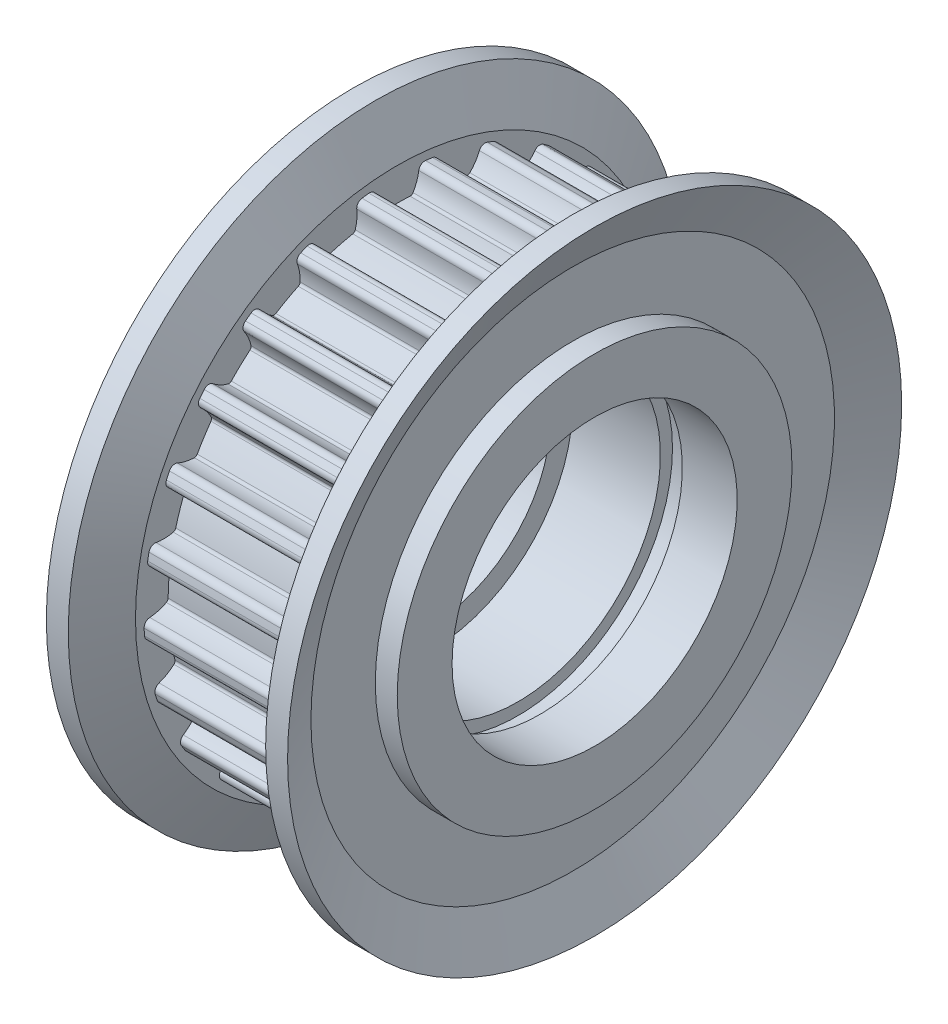
from build123d import *

# Parameters (mm, degrees)
CUT_EXTRUDE1_DEPTH  = 7
CUT_EXTRUDE2_DEPTH  = 7
CUT_EXTRUDE3_DEPTH  = 7
CUT_EXTRUDE4_DEPTH  = 7
CUT_EXTRUDE5_DEPTH  = 7
CUT_EXTRUDE6_DEPTH  = 7
CUT_EXTRUDE7_DEPTH  = 7
CUT_EXTRUDE8_DEPTH  = 7
CUT_EXTRUDE9_DEPTH  = 7
CUT_EXTRUDE10_DEPTH = 7
CUT_EXTRUDE11_DEPTH = 7
CUT_EXTRUDE12_DEPTH = 7
CUT_EXTRUDE13_DEPTH = 7
CUT_EXTRUDE14_DEPTH = 7
CUT_EXTRUDE15_DEPTH = 7
CUT_EXTRUDE16_DEPTH = 7
CUT_EXTRUDE17_DEPTH = 7
CUT_EXTRUDE18_DEPTH = 7
CUT_EXTRUDE19_DEPTH = 7
CUT_EXTRUDE20_DEPTH = 7
CUT_EXTRUDE21_DEPTH = 7
CUT_EXTRUDE22_DEPTH = 7
CUT_EXTRUDE23_DEPTH = 7
CUT_EXTRUDE24_DEPTH = 7
CUT_EXTRUDE25_DEPTH = 7


with BuildPart() as part:
    # Sketch1 → Revolve1 (revolve)
    with BuildSketch(Plane.XY):
        Polygon((-5.5, 5.5), (-2, 5.5), (-2, 6.5), (2, 6.5), (2, 7.05), (3, 7.05), (3, 6.5), (5.5, 6.5), (5.5, 9), (4.5, 9), (4.5, 11.935), (5.5, 14), (4.5, 14), (3.5, 11.935), (3.5, 11.555), (-3.5, 11.555), (-3.5, 11.935), (-4.5, 14), (-5.5, 14), (-4.5, 11.935), (-4.5, 9), (-5.5, 9), align=None)
    revolve(axis=Axis((11, 0, 0), (-1, 0, 0)))

    # Sketch2 → Cut-Extrude1 (cut)
    with BuildSketch(Plane(origin=(3.5, 0, 0), x_dir=(0, 0, -1), z_dir=(1, 0, 0))):
        with BuildLine():
            Line((1.289949408, 11.482772118), (1.289949408, 12.34518952))
            ThreePointArc((1.289949408, 12.34518952), (0, 12.4124), (-1.289949408, 12.34518952))
            Line((-1.289949408, 12.34518952), (-1.289949408, 11.482772118))
            ThreePointArc((-1.289949408, 11.482772118), (-1.086869936, 11.425604612), (-0.981337291, 11.24292386))
            ThreePointArc((-0.981337291, 11.24292386), (-0.888352706, 10.859160772), (-0.720884057, 10.50156534))
            ThreePointArc((-0.720884057, 10.50156534), (-0.66246262, 10.445979458), (-0.583700291, 10.428677719))
            ThreePointArc((-0.583700291, 10.428677719), (-1.15e-07, 10.445), (0.583700061, 10.428677732))
            ThreePointArc((0.583700061, 10.428677732), (0.662462531, 10.445979411), (0.720884072, 10.501565366))
            ThreePointArc((0.720884072, 10.501565366), (0.888352711, 10.859160786), (0.981337291, 11.24292386))
            ThreePointArc((0.981337291, 11.24292386), (1.086869936, 11.425604612), (1.289949408, 11.482772118))
        make_face()
    extrude(amount=-CUT_EXTRUDE1_DEPTH, mode=Mode.SUBTRACT)

    # Sketch3 → Cut-Extrude2 (cut)
    with BuildSketch(Plane(origin=(3.5, 0, 0), x_dir=(0, 0, -1), z_dir=(1, 0, 0))):
        with BuildLine():
            Line((4.105072578, 10.801222344), (4.319547064, 11.636545317))
            ThreePointArc((4.319547064, 11.636545317), (3.086838355, 12.022441629), (1.820700513, 12.278140063))
            Line((1.820700513, 12.278140063), (1.606226027, 11.44281709))
            ThreePointArc((1.606226027, 11.44281709), (1.788708404, 11.336941794), (1.845494691, 11.133755393))
            ThreePointArc((1.845494691, 11.133755393), (1.840119994, 10.738924602), (1.913396941, 10.350915929))
            ThreePointArc((1.913396941, 10.350915929), (1.956159314, 10.282547559), (2.028144412, 10.246201991))
            ThreePointArc((2.028144412, 10.246201991), (2.59756576, 10.116851147), (3.158868739, 9.955881342))
            ThreePointArc((3.158868739, 9.955881342), (3.239459494, 9.953052027), (3.30986928, 9.9923628))
            ThreePointArc((3.30986928, 9.9923628), (3.561006948, 10.297075946), (3.746508242, 10.645658073))
            ThreePointArc((3.746508242, 10.645658073), (3.89415624, 10.796354671), (4.105072578, 10.801222344))
        make_face()
    extrude(amount=-CUT_EXTRUDE2_DEPTH, mode=Mode.SUBTRACT)

    # Sketch4 → Cut-Extrude3 (cut)
    with BuildSketch(Plane(origin=(3.5, 0, 0), x_dir=(0, 0, -1), z_dir=(1, 0, 0))):
        with BuildLine():
            Line((6.66225894, 9.440992046), (7.077731692, 10.196734176))
            ThreePointArc((7.077731692, 10.196734176), (5.979719304, 10.877069035), (4.816949125, 11.43960991))
            Line((4.816949125, 11.43960991), (4.401476374, 10.68386778))
            ThreePointArc((4.401476374, 10.68386778), (4.551895616, 10.53593723), (4.556367454, 10.325012128))
            ThreePointArc((4.556367454, 10.325012128), (4.452971189, 9.943922304), (4.427452171, 9.549880401))
            ThreePointArc((4.427452171, 9.549880401), (4.451868564, 9.47302538), (4.512553343, 9.419919709))
            ThreePointArc((4.512553343, 9.419919709), (5.031917025, 9.153023329), (5.535554076, 8.857520312))
            ThreePointArc((5.535554076, 8.857520312), (5.612909302, 8.834737779), (5.690883227, 8.85530333))
            ThreePointArc((5.690883227, 8.85530333), (6.009910021, 9.087987954), (6.276272301, 9.379486437))
            ThreePointArc((6.276272301, 9.379486437), (6.456758386, 9.48873006), (6.66225894, 9.440992046))
        make_face()
    extrude(amount=-CUT_EXTRUDE3_DEPTH, mode=Mode.SUBTRACT)

    # Sketch5 → Cut-Extrude4 (cut)
    with BuildSketch(Plane(origin=(3.5, 0, 0), x_dir=(0, 0, -1), z_dir=(1, 0, 0))):
        with BuildLine():
            Line((8.800831071, 7.487549496), (9.391196408, 8.116224726))
            ThreePointArc((9.391196408, 8.116224726), (8.496872498, 9.048250191), (7.510531109, 9.882286994))
            Line((7.510531109, 9.882286994), (6.920165772, 9.253611764))
            ThreePointArc((6.920165772, 9.253611764), (7.029070485, 9.07292098), (6.980946893, 8.867510377))
            ThreePointArc((6.980946893, 8.867510377), (6.786025826, 8.524106797), (6.663314299, 8.148790767))
            ThreePointArc((6.663314299, 8.148790767), (6.66785054, 8.068278177), (6.713421951, 8.001749228))
            ThreePointArc((6.713421951, 8.001749228), (7.150094437, 7.614077392), (7.564420192, 7.202608705))
            ThreePointArc((7.564420192, 7.202608705), (7.633679376, 7.161304465), (7.714318052, 7.161832585))
            ThreePointArc((7.714318052, 7.161832585), (8.081188345, 7.307868255), (8.411675089, 7.523967172))
            ThreePointArc((8.411675089, 7.523967172), (8.613658656, 7.584893642), (8.800831071, 7.487549496))
        make_face()
    extrude(amount=-CUT_EXTRUDE4_DEPTH, mode=Mode.SUBTRACT)

    # Sketch6 → Cut-Extrude5 (cut)
    with BuildSketch(Plane(origin=(3.5, 0, 0), x_dir=(0, 0, -1), z_dir=(1, 0, 0))):
        with BuildLine():
            Line((10.386414619, 5.063636674), (11.114577714, 5.525743026))
            ThreePointArc((11.114577714, 5.525743026), (10.480135943, 6.65089651), (9.7321988, 7.704023642))
            Line((9.7321988, 7.704023642), (9.004035705, 7.241917289))
            ThreePointArc((9.004035705, 7.241917289), (9.064583005, 7.039819738), (8.966887764, 6.852830338))
            ThreePointArc((8.966887764, 6.852830338), (8.692689504, 6.56869031), (8.480495884, 6.235682639))
            ThreePointArc((8.480495884, 6.235682639), (8.464866943, 6.156571383), (8.492461568, 6.080799414))
            ThreePointArc((8.492461568, 6.080799414), (8.81900512, 5.596710971), (9.117985968, 5.095130704))
            ThreePointArc((9.117985968, 5.095130704), (9.174797301, 5.037900054), (9.253033902, 5.018357559))
            ThreePointArc((9.253033902, 5.018357559), (9.644695885, 5.068568318), (10.018541395, 5.195689379))
            ThreePointArc((10.018541395, 5.195689379), (10.229331074, 5.204470462), (10.386414619, 5.063636674))
        make_face()
    extrude(amount=-CUT_EXTRUDE5_DEPTH, mode=Mode.SUBTRACT)

    # Sketch7 → Cut-Extrude6 (cut)
    with BuildSketch(Plane(origin=(3.5, 0, 0), x_dir=(0, 0, -1), z_dir=(1, 0, 0))):
        with BuildLine():
            Line((11.319381537, 2.321556937), (12.139589227, 2.58805857))
            ThreePointArc((12.139589227, 2.58805857), (11.804893903, 3.835642541), (11.342356649, 5.041688151))
            Line((11.342356649, 5.041688151), (10.522148959, 4.775186517))
            ThreePointArc((10.522148959, 4.775186517), (10.530534438, 4.564380731), (10.389406099, 4.407561765))
            ThreePointArc((10.389406099, 4.407561765), (10.05315953, 4.200538853), (9.764816723, 3.930763638))
            ThreePointArc((9.764816723, 3.930763638), (9.730004625, 3.858024567), (9.737888591, 3.77777061))
            ThreePointArc((9.737888591, 3.77777061), (9.933785277, 3.227682616), (10.098635152, 2.667506902))
            ThreePointArc((10.098635152, 2.667506902), (10.139428968, 2.597945854), (10.210347602, 2.559560671))
            ThreePointArc((10.210347602, 2.559560671), (10.602191712, 2.510791593), (10.9959059, 2.540947314))
            ThreePointArc((10.9959059, 2.540947314), (11.202256999, 2.497031261), (11.319381537, 2.321556937))
        make_face()
    extrude(amount=-CUT_EXTRUDE6_DEPTH, mode=Mode.SUBTRACT)

    # Sketch8 → Cut-Extrude7 (cut)
    with BuildSketch(Plane(origin=(3.5, 0, 0), x_dir=(0, 0, -1), z_dir=(1, 0, 0))):
        with BuildLine():
            Line((11.541110084, -0.566394761), (12.401825702, -0.512243124))
            ThreePointArc((12.401825702, -0.512243124), (12.387906964, 0.779381045), (12.239832515, 2.062564851))
            Line((12.239832515, 2.062564851), (11.379116897, 2.008413215))
            ThreePointArc((11.379116897, 2.008413215), (11.334813663, 1.802144896), (11.15911984, 1.685349877))
            ThreePointArc((11.15911984, 1.685349877), (10.781952571, 1.568452092), (10.435578215, 1.378860301))
            ThreePointArc((10.435578215, 1.378860301), (10.383770332, 1.317063879), (10.371448261, 1.237370584))
            ThreePointArc((10.371448261, 1.237370584), (10.424389171, 0.655847092), (10.444749949, 0.072273831))
            ThreePointArc((10.444749949, 0.072273831), (10.466963023, -0.005246839), (10.526107611, -0.060062827))
            ThreePointArc((10.526107611, -0.060062827), (10.893512841, -0.204747403), (11.282357197, -0.273451816))
            ThreePointArc((11.282357197, -0.273451816), (11.471303919, -0.367305597), (11.541110084, -0.566394761))
        make_face()
    extrude(amount=-CUT_EXTRUDE7_DEPTH, mode=Mode.SUBTRACT)

    # Sketch9 → Cut-Extrude8 (cut)
    with BuildSketch(Plane(origin=(3.5, 0, 0), x_dir=(0, 0, -1), z_dir=(1, 0, 0))):
        with BuildLine():
            Line((11.037668239, -3.418757792), (11.884809857, -3.580358699))
            ThreePointArc((11.884809857, -3.580358699), (12.192542271, -2.325851829), (12.368234689, -1.046156983))
            Line((12.368234689, -1.046156983), (11.521093071, -0.884556077))
            ThreePointArc((11.521093071, -0.884556077), (11.426884859, -1.073326331), (11.227665041, -1.142758743))
            ThreePointArc((11.227665041, -1.142758743), (10.833275878, -1.162186283), (10.450633948, -1.2596819))
            ThreePointArc((10.450633948, -1.2596819), (10.38508556, -1.306652777), (10.353331693, -1.380777986))
            ThreePointArc((10.353331693, -1.380777986), (10.259990356, -1.957197717), (10.134582693, -2.527500471))
            ThreePointArc((10.134582693, -2.527500471), (10.136819297, -2.608109853), (10.180473566, -2.675912357))
            ThreePointArc((10.180473566, -2.675912357), (10.500354495, -2.907421366), (10.859896497, -3.070668963))
            ThreePointArc((10.859896497, -3.070668963), (11.019566625, -3.208563293), (11.037668239, -3.418757792))
        make_face()
    extrude(amount=-CUT_EXTRUDE8_DEPTH, mode=Mode.SUBTRACT)

    # Sketch10 → Cut-Extrude9 (cut)
    with BuildSketch(Plane(origin=(3.5, 0, 0), x_dir=(0, 0, -1), z_dir=(1, 0, 0))):
        with BuildLine():
            Line((9.840689105, -6.056307699), (10.6210277, -6.423507169))
            ThreePointArc((10.6210277, -6.423507169), (11.231075306, -5.284942879), (11.719495191, -4.089144927))
            Line((11.719495191, -4.089144927), (10.939156595, -3.721945457))
            ThreePointArc((10.939156595, -3.721945457), (10.800962855, -3.881356517), (10.590734754, -3.899063628))
            ThreePointArc((10.590734754, -3.899063628), (10.203904619, -3.819800219), (9.809037916, -3.819073654))
            ThreePointArc((9.809037916, -3.819073654), (9.733867668, -3.848267634), (9.684677218, -3.912167197))
            ThreePointArc((9.684677218, -3.912167197), (9.450918612, -4.447264596), (9.187622335, -4.968462622))
            ThreePointArc((9.187622335, -4.968462622), (9.169741933, -5.047095733), (9.195162926, -5.123624472))
            ThreePointArc((9.195162926, -5.123624472), (9.447420258, -5.427411352), (9.755068561, -5.674944685))
            ThreePointArc((9.755068561, -5.674944685), (9.875429432, -5.848215158), (9.840689105, -6.056307699))
        make_face()
    extrude(amount=-CUT_EXTRUDE9_DEPTH, mode=Mode.SUBTRACT)

    # Sketch11 → Cut-Extrude10 (cut)
    with BuildSketch(Plane(origin=(3.5, 0, 0), x_dir=(0, 0, -1), z_dir=(1, 0, 0))):
        with BuildLine():
            Line((8.025383283, -8.313317519), (8.689887311, -8.86304306))
            ThreePointArc((8.689887311, -8.86304306), (9.563918575, -7.91196153), (10.334376708, -6.875196857))
            Line((10.334376708, -6.875196857), (9.669872679, -6.325471316))
            ThreePointArc((9.669872679, -6.325471316), (9.496376631, -6.445506798), (9.288349654, -6.410376005))
            ThreePointArc((9.288349654, -6.410376005), (8.933384506, -6.23740206), (8.551103956, -6.138498965))
            ThreePointArc((8.551103956, -6.138498965), (8.471035073, -6.148081681), (8.407498856, -6.197740555))
            ThreePointArc((8.407498856, -6.197740555), (8.048010894, -6.657893484), (7.663369876, -7.097237994))
            ThreePointArc((7.663369876, -7.097237994), (7.62649596, -7.168954026), (7.632086382, -7.249400418))
            ThreePointArc((7.632086382, -7.249400418), (7.800869861, -7.606377122), (8.037293791, -7.922642762))
            ThreePointArc((8.037293791, -7.922642762), (8.110782689, -8.120402156), (8.025383283, -8.313317519))
        make_face()
    extrude(amount=-CUT_EXTRUDE10_DEPTH, mode=Mode.SUBTRACT)

    # Sketch12 → Cut-Extrude11 (cut)
    with BuildSketch(Plane(origin=(3.5, 0, 0), x_dir=(0, 0, -1), z_dir=(1, 0, 0))):
        with BuildLine():
            Line((5.705813114, -10.047971025), (6.212729344, -10.745681359))
            ThreePointArc((6.212729344, -10.745681359), (7.295825666, -10.041842541), (8.29991133, -9.229254882))
            Line((8.29991133, -9.229254882), (7.7929951, -8.531544548))
            ThreePointArc((7.7929951, -8.531544548), (7.595098138, -8.604662183), (7.402343384, -8.518900882))
            ThreePointArc((7.402343384, -8.518900882), (7.10154699, -8.263084989), (6.755872686, -8.07221981))
            ThreePointArc((6.755872686, -8.07221981), (6.675936189, -8.061589146), (6.60204642, -8.093887081))
            ThreePointArc((6.60204642, -8.093887081), (6.139417054, -8.450182438), (5.657599703, -8.780067802))
            ThreePointArc((5.657599703, -8.780067802), (5.604049198, -8.840360572), (5.589457782, -8.919669875))
            ThreePointArc((5.589457782, -8.919669875), (5.664162122, -9.307406243), (5.814506292, -9.672532057))
            ThreePointArc((5.814506292, -9.672532057), (5.836505641, -9.882354421), (5.705813114, -10.047971025))
        make_face()
    extrude(amount=-CUT_EXTRUDE11_DEPTH, mode=Mode.SUBTRACT)

    # Sketch13 → Cut-Extrude12 (cut)
    with BuildSketch(Plane(origin=(3.5, 0, 0), x_dir=(0, 0, -1), z_dir=(1, 0, 0))):
        with BuildLine():
            Line((3.027725722, -11.151273557), (3.345202742, -11.953128978))
            ThreePointArc((3.345202742, -11.953128978), (4.569309198, -11.540757653), (5.743931998, -11.003404881))
            Line((5.743931998, -11.003404881), (5.426454977, -10.20154946))
            ThreePointArc((5.426454977, -10.20154946), (5.216591696, -10.223154996), (5.051220655, -10.092151887))
            ThreePointArc((5.051220655, -10.092151887), (4.823493159, -9.769567899), (4.536145089, -9.498733397))
            ThreePointArc((4.536145089, -9.498733397), (4.461363682, -9.468557317), (4.381763126, -9.481464913))
            ThreePointArc((4.381763126, -9.481464913), (3.84506106, -9.711515353), (3.296341734, -9.911213658))
            ThreePointArc((3.296341734, -9.911213658), (3.229479414, -9.956294751), (3.195622993, -10.029483669))
            ThreePointArc((3.195622993, -10.029483669), (3.171554245, -10.4236168), (3.226371979, -10.814660589))
            ThreePointArc((3.226371979, -10.814660589), (3.195499477, -11.023362014), (3.027725722, -11.151273557))
        make_face()
    extrude(amount=-CUT_EXTRUDE12_DEPTH, mode=Mode.SUBTRACT)

    # Sketch14 → Cut-Extrude13 (cut)
    with BuildSketch(Plane(origin=(3.5, 0, 0), x_dir=(0, 0, -1), z_dir=(1, 0, 0))):
        with BuildLine():
            Line((0.159395188, -11.553900561), (0.26748475, -12.409517544))
            ThreePointArc((0.26748475, -12.409517544), (1.555686228, -12.314524519), (2.827040293, -12.086170483))
            Line((2.827040293, -12.086170483), (2.718950732, -11.2305535))
            ThreePointArc((2.718950732, -11.2305535), (2.510307613, -11.199289383), (2.382711156, -11.031275872))
            ThreePointArc((2.382711156, -11.031275872), (2.242361513, -10.662192928), (2.031394813, -10.328406631))
            ThreePointArc((2.031394813, -10.328406631), (1.966467288, -10.280581208), (1.886157541, -10.273287435))
            ThreePointArc((1.886157541, -10.273287435), (1.309105739, -10.362638041), (0.72796249, -10.419601509))
            ThreePointArc((0.72796249, -10.419601509), (0.651989561, -10.446638314), (0.600995459, -10.509108118))
            ThreePointArc((0.600995459, -10.509108118), (0.47966595, -10.884873177), (0.435512849, -11.277264224))
            ThreePointArc((0.435512849, -11.277264224), (0.35370833, -11.47173123), (0.159395188, -11.553900561))
        make_face()
    extrude(amount=-CUT_EXTRUDE13_DEPTH, mode=Mode.SUBTRACT)

    # Sketch15 → Cut-Extrude14 (cut)
    with BuildSketch(Plane(origin=(3.5, 0, 0), x_dir=(0, 0, -1), z_dir=(1, 0, 0))):
        with BuildLine():
            Line((-2.718950732, -11.2305535), (-2.827040293, -12.086170483))
            ThreePointArc((-2.827040293, -12.086170483), (-1.555686228, -12.314524519), (-0.26748475, -12.409517544))
            Line((-0.26748475, -12.409517544), (-0.159395188, -11.553900561))
            ThreePointArc((-0.159395188, -11.553900561), (-0.35370833, -11.47173123), (-0.435512849, -11.277264224))
            ThreePointArc((-0.435512849, -11.277264224), (-0.479665953, -10.884873163), (-0.60099547, -10.50910809))
            ThreePointArc((-0.60099547, -10.50910809), (-0.651989479, -10.446638372), (-0.72796226, -10.419601525))
            ThreePointArc((-0.72796226, -10.419601525), (-1.30910551, -10.36263807), (-1.886157313, -10.273287477))
            ThreePointArc((-1.886157313, -10.273287477), (-1.966467194, -10.280581172), (-2.031394831, -10.328406654))
            ThreePointArc((-2.031394831, -10.328406654), (-2.24236152, -10.662192942), (-2.382711156, -11.031275872))
            ThreePointArc((-2.382711156, -11.031275872), (-2.510307613, -11.199289383), (-2.718950732, -11.2305535))
        make_face()
    extrude(amount=-CUT_EXTRUDE14_DEPTH, mode=Mode.SUBTRACT)

    # Sketch16 → Cut-Extrude15 (cut)
    with BuildSketch(Plane(origin=(3.5, 0, 0), x_dir=(0, 0, -1), z_dir=(1, 0, 0))):
        with BuildLine():
            Line((-5.426454977, -10.20154946), (-5.743931998, -11.003404881))
            ThreePointArc((-5.743931998, -11.003404881), (-4.569309198, -11.540757653), (-3.345202742, -11.953128978))
            Line((-3.345202742, -11.953128978), (-3.027725722, -11.151273557))
            ThreePointArc((-3.027725722, -11.151273557), (-3.195499477, -11.023362014), (-3.226371979, -10.814660589))
            ThreePointArc((-3.226371979, -10.814660589), (-3.171554244, -10.423616785), (-3.195622998, -10.029483639))
            ThreePointArc((-3.195622998, -10.029483639), (-3.229479349, -9.956294828), (-3.296341515, -9.911213731))
            ThreePointArc((-3.296341515, -9.911213731), (-3.845060845, -9.711515438), (-4.381762917, -9.48146501))
            ThreePointArc((-4.381762917, -9.48146501), (-4.461363582, -9.468557305), (-4.536145112, -9.498733415))
            ThreePointArc((-4.536145112, -9.498733415), (-4.823493169, -9.769567911), (-5.051220655, -10.092151887))
            ThreePointArc((-5.051220655, -10.092151887), (-5.216591696, -10.223154996), (-5.426454977, -10.20154946))
        make_face()
    extrude(amount=-CUT_EXTRUDE15_DEPTH, mode=Mode.SUBTRACT)

    # Sketch17 → Cut-Extrude16 (cut)
    with BuildSketch(Plane(origin=(3.5, 0, 0), x_dir=(0, 0, -1), z_dir=(1, 0, 0))):
        with BuildLine():
            Line((-7.7929951, -8.531544548), (-8.29991133, -9.229254882))
            ThreePointArc((-8.29991133, -9.229254882), (-7.295825666, -10.041842541), (-6.212729344, -10.745681359))
            Line((-6.212729344, -10.745681359), (-5.705813114, -10.047971025))
            ThreePointArc((-5.705813114, -10.047971025), (-5.836505641, -9.882354421), (-5.814506292, -9.672532057))
            ThreePointArc((-5.814506292, -9.672532057), (-5.664162117, -9.307406229), (-5.58945778, -8.919669845))
            ThreePointArc((-5.58945778, -8.919669845), (-5.604049154, -8.840360663), (-5.657599509, -8.780067927))
            ThreePointArc((-5.657599509, -8.780067927), (-6.139416867, -8.450182574), (-6.602046241, -8.093887227))
            ThreePointArc((-6.602046241, -8.093887227), (-6.675936089, -8.06158916), (-6.755872713, -8.072219822))
            ThreePointArc((-6.755872713, -8.072219822), (-7.101547003, -8.263084998), (-7.402343384, -8.518900882))
            ThreePointArc((-7.402343384, -8.518900882), (-7.595098138, -8.604662183), (-7.7929951, -8.531544548))
        make_face()
    extrude(amount=-CUT_EXTRUDE16_DEPTH, mode=Mode.SUBTRACT)

    # Sketch18 → Cut-Extrude17 (cut)
    with BuildSketch(Plane(origin=(3.5, 0, 0), x_dir=(0, 0, -1), z_dir=(1, 0, 0))):
        with BuildLine():
            Line((-9.669872679, -6.325471316), (-10.334376708, -6.875196857))
            ThreePointArc((-10.334376708, -6.875196857), (-9.563918575, -7.91196153), (-8.689887311, -8.86304306))
            Line((-8.689887311, -8.86304306), (-8.025383283, -8.313317519))
            ThreePointArc((-8.025383283, -8.313317519), (-8.110782689, -8.120402156), (-8.037293791, -7.922642762))
            ThreePointArc((-8.037293791, -7.922642762), (-7.800869854, -7.606377109), (-7.632086372, -7.24940039))
            ThreePointArc((-7.632086372, -7.24940039), (-7.62649594, -7.168954125), (-7.663369719, -7.097238164))
            ThreePointArc((-7.663369719, -7.097238164), (-8.048010747, -6.657893662), (-8.407498719, -6.197740741))
            ThreePointArc((-8.407498719, -6.197740741), (-8.47103498, -6.14808172), (-8.551103986, -6.13849897))
            ThreePointArc((-8.551103986, -6.13849897), (-8.93338452, -6.237402065), (-9.288349654, -6.410376005))
            ThreePointArc((-9.288349654, -6.410376005), (-9.496376631, -6.445506798), (-9.669872679, -6.325471316))
        make_face()
    extrude(amount=-CUT_EXTRUDE17_DEPTH, mode=Mode.SUBTRACT)

    # Sketch19 → Cut-Extrude18 (cut)
    with BuildSketch(Plane(origin=(3.5, 0, 0), x_dir=(0, 0, -1), z_dir=(1, 0, 0))):
        with BuildLine():
            Line((-10.939156595, -3.721945457), (-11.719495191, -4.089144927))
            ThreePointArc((-11.719495191, -4.089144927), (-11.231075306, -5.284942879), (-10.6210277, -6.423507169))
            Line((-10.6210277, -6.423507169), (-9.840689105, -6.056307699))
            ThreePointArc((-9.840689105, -6.056307699), (-9.875429432, -5.848215158), (-9.755068561, -5.674944685))
            ThreePointArc((-9.755068561, -5.674944685), (-9.447420247, -5.427411341), (-9.19516291, -5.123624447))
            ThreePointArc((-9.19516291, -5.123624447), (-9.169741938, -5.047095833), (-9.187622225, -4.968462825))
            ThreePointArc((-9.187622225, -4.968462825), (-9.450918514, -4.447264805), (-9.684677132, -3.912167411))
            ThreePointArc((-9.684677132, -3.912167411), (-9.733867588, -3.848267694), (-9.809037946, -3.819073651))
            ThreePointArc((-9.809037946, -3.819073651), (-10.203904634, -3.819800221), (-10.590734754, -3.899063628))
            ThreePointArc((-10.590734754, -3.899063628), (-10.800962855, -3.881356517), (-10.939156595, -3.721945457))
        make_face()
    extrude(amount=-CUT_EXTRUDE18_DEPTH, mode=Mode.SUBTRACT)

    # Sketch20 → Cut-Extrude19 (cut)
    with BuildSketch(Plane(origin=(3.5, 0, 0), x_dir=(0, 0, -1), z_dir=(1, 0, 0))):
        with BuildLine():
            Line((-11.521093071, -0.884556077), (-12.368234689, -1.046156983))
            ThreePointArc((-12.368234689, -1.046156983), (-12.192542271, -2.325851829), (-11.884809857, -3.580358699))
            Line((-11.884809857, -3.580358699), (-11.037668239, -3.418757792))
            ThreePointArc((-11.037668239, -3.418757792), (-11.019566625, -3.208563293), (-10.859896497, -3.070668963))
            ThreePointArc((-10.859896497, -3.070668963), (-10.500354482, -2.907421358), (-10.180473544, -2.675912337))
            ThreePointArc((-10.180473544, -2.675912337), (-10.136819327, -2.608109949), (-10.134582638, -2.527500695))
            ThreePointArc((-10.134582638, -2.527500695), (-10.259990312, -1.957197944), (-10.353331663, -1.380778215))
            ThreePointArc((-10.353331663, -1.380778215), (-10.385085497, -1.306652856), (-10.450633976, -1.25968189))
            ThreePointArc((-10.450633976, -1.25968189), (-10.833275892, -1.162186281), (-11.227665041, -1.142758743))
            ThreePointArc((-11.227665041, -1.142758743), (-11.426884859, -1.073326331), (-11.521093071, -0.884556077))
        make_face()
    extrude(amount=-CUT_EXTRUDE19_DEPTH, mode=Mode.SUBTRACT)

    # Sketch21 → Cut-Extrude20 (cut)
    with BuildSketch(Plane(origin=(3.5, 0, 0), x_dir=(0, 0, -1), z_dir=(1, 0, 0))):
        with BuildLine():
            Line((-11.379116897, 2.008413215), (-12.239832515, 2.062564851))
            ThreePointArc((-12.239832515, 2.062564851), (-12.387906964, 0.779381045), (-12.401825702, -0.512243124))
            Line((-12.401825702, -0.512243124), (-11.541110084, -0.566394761))
            ThreePointArc((-11.541110084, -0.566394761), (-11.471303919, -0.367305597), (-11.282357197, -0.273451816))
            ThreePointArc((-11.282357197, -0.273451816), (-10.893512826, -0.204747399), (-10.526107584, -0.060062814))
            ThreePointArc((-10.526107584, -0.060062814), (-10.466963076, -0.005246924), (-10.44474995, 0.0722736))
            ThreePointArc((-10.44474995, 0.0722736), (-10.424389186, 0.655846861), (-10.371448289, 1.237370355))
            ThreePointArc((-10.371448289, 1.237370355), (-10.38377029, 1.317063787), (-10.43557824, 1.378860318))
            ThreePointArc((-10.43557824, 1.378860318), (-10.781952584, 1.568452098), (-11.15911984, 1.685349877))
            ThreePointArc((-11.15911984, 1.685349877), (-11.334813663, 1.802144896), (-11.379116897, 2.008413215))
        make_face()
    extrude(amount=-CUT_EXTRUDE20_DEPTH, mode=Mode.SUBTRACT)

    # Sketch22 → Cut-Extrude21 (cut)
    with BuildSketch(Plane(origin=(3.5, 0, 0), x_dir=(0, 0, -1), z_dir=(1, 0, 0))):
        with BuildLine():
            Line((-10.522148959, 4.775186517), (-11.342356649, 5.041688151))
            ThreePointArc((-11.342356649, 5.041688151), (-11.804893903, 3.835642541), (-12.139589227, 2.58805857))
            Line((-12.139589227, 2.58805857), (-11.319381537, 2.321556937))
            ThreePointArc((-11.319381537, 2.321556937), (-11.202256999, 2.497031261), (-10.9959059, 2.540947314))
            ThreePointArc((-10.9959059, 2.540947314), (-10.602191697, 2.510791593), (-10.210347573, 2.559560677))
            ThreePointArc((-10.210347573, 2.559560677), (-10.139429041, 2.597945784), (-10.098635211, 2.667506678))
            ThreePointArc((-10.098635211, 2.667506678), (-9.933785348, 3.227682396), (-9.737888675, 3.777770395))
            ThreePointArc((-9.737888675, 3.777770395), (-9.730004608, 3.858024468), (-9.764816743, 3.93076366))
            ThreePointArc((-9.764816743, 3.93076366), (-10.053159542, 4.200538862), (-10.389406099, 4.407561765))
            ThreePointArc((-10.389406099, 4.407561765), (-10.530534438, 4.564380731), (-10.522148959, 4.775186517))
        make_face()
    extrude(amount=-CUT_EXTRUDE21_DEPTH, mode=Mode.SUBTRACT)

    # Sketch23 → Cut-Extrude22 (cut)
    with BuildSketch(Plane(origin=(3.5, 0, 0), x_dir=(0, 0, -1), z_dir=(1, 0, 0))):
        with BuildLine():
            Line((-9.004035705, 7.241917289), (-9.7321988, 7.704023642))
            ThreePointArc((-9.7321988, 7.704023642), (-10.480135943, 6.65089651), (-11.114577714, 5.525743026))
            Line((-11.114577714, 5.525743026), (-10.386414619, 5.063636674))
            ThreePointArc((-10.386414619, 5.063636674), (-10.229331074, 5.204470462), (-10.018541395, 5.195689379))
            ThreePointArc((-10.018541395, 5.195689379), (-9.644695871, 5.068568315), (-9.253033872, 5.018357558))
            ThreePointArc((-9.253033872, 5.018357558), (-9.174797388, 5.037900004), (-9.117986081, 5.095130502))
            ThreePointArc((-9.117986081, 5.095130502), (-8.819005244, 5.596710776), (-8.492461702, 6.080799227))
            ThreePointArc((-8.492461702, 6.080799227), (-8.464866951, 6.156571283), (-8.480495898, 6.235682666))
            ThreePointArc((-8.480495898, 6.235682666), (-8.692689513, 6.568690322), (-8.966887764, 6.852830338))
            ThreePointArc((-8.966887764, 6.852830338), (-9.064583005, 7.039819738), (-9.004035705, 7.241917289))
        make_face()
    extrude(amount=-CUT_EXTRUDE22_DEPTH, mode=Mode.SUBTRACT)

    # Sketch24 → Cut-Extrude23 (cut)
    with BuildSketch(Plane(origin=(3.5, 0, 0), x_dir=(0, 0, -1), z_dir=(1, 0, 0))):
        with BuildLine():
            Line((-6.920165772, 9.253611764), (-7.510531109, 9.882286994))
            ThreePointArc((-7.510531109, 9.882286994), (-8.496872498, 9.048250191), (-9.391196408, 8.116224726))
            Line((-9.391196408, 8.116224726), (-8.800831071, 7.487549496))
            ThreePointArc((-8.800831071, 7.487549496), (-8.613658656, 7.584893642), (-8.411675089, 7.523967172))
            ThreePointArc((-8.411675089, 7.523967172), (-8.081188332, 7.307868248), (-7.714318023, 7.161832577))
            ThreePointArc((-7.714318023, 7.161832577), (-7.633679474, 7.161304438), (-7.564420352, 7.202608537))
            ThreePointArc((-7.564420352, 7.202608537), (-7.150094606, 7.614077234), (-6.713422128, 8.00174908))
            ThreePointArc((-6.713422128, 8.00174908), (-6.667850572, 8.068278082), (-6.663314306, 8.148790796))
            ThreePointArc((-6.663314306, 8.148790796), (-6.786025832, 8.524106811), (-6.980946893, 8.867510377))
            ThreePointArc((-6.980946893, 8.867510377), (-7.029070485, 9.07292098), (-6.920165772, 9.253611764))
        make_face()
    extrude(amount=-CUT_EXTRUDE23_DEPTH, mode=Mode.SUBTRACT)

    # Sketch25 → Cut-Extrude24 (cut)
    with BuildSketch(Plane(origin=(3.5, 0, 0), x_dir=(0, 0, -1), z_dir=(1, 0, 0))):
        with BuildLine():
            Line((-4.401476374, 10.68386778), (-4.816949125, 11.43960991))
            ThreePointArc((-4.816949125, 11.43960991), (-5.979719304, 10.877069035), (-7.077731692, 10.196734176))
            Line((-7.077731692, 10.196734176), (-6.66225894, 9.440992046))
            ThreePointArc((-6.66225894, 9.440992046), (-6.456758386, 9.48873006), (-6.276272301, 9.379486437))
            ThreePointArc((-6.276272301, 9.379486437), (-6.00991001, 9.087987944), (-5.690883201, 8.855303315))
            ThreePointArc((-5.690883201, 8.855303315), (-5.612909403, 8.834737778), (-5.535554272, 8.857520189))
            ThreePointArc((-5.535554272, 8.857520189), (-5.031917227, 9.153023217), (-4.512553551, 9.41991961))
            ThreePointArc((-4.512553551, 9.41991961), (-4.451868619, 9.473025296), (-4.42745217, 9.549880431))
            ThreePointArc((-4.42745217, 9.549880431), (-4.452971191, 9.943922319), (-4.556367454, 10.325012128))
            ThreePointArc((-4.556367454, 10.325012128), (-4.551895616, 10.53593723), (-4.401476374, 10.68386778))
        make_face()
    extrude(amount=-CUT_EXTRUDE24_DEPTH, mode=Mode.SUBTRACT)

    # Sketch26 → Cut-Extrude25 (cut)
    with BuildSketch(Plane(origin=(3.5, 0, 0), x_dir=(0, 0, -1), z_dir=(1, 0, 0))):
        with BuildLine():
            Line((-1.606226027, 11.44281709), (-1.820700513, 12.278140063))
            ThreePointArc((-1.820700513, 12.278140063), (-3.086838355, 12.022441629), (-4.319547064, 11.636545317))
            Line((-4.319547064, 11.636545317), (-4.105072578, 10.801222344))
            ThreePointArc((-4.105072578, 10.801222344), (-3.89415624, 10.796354671), (-3.746508242, 10.645658073))
            ThreePointArc((-3.746508242, 10.645658073), (-3.56100694, 10.297075933), (-3.309869258, 9.992362779))
            ThreePointArc((-3.309869258, 9.992362779), (-3.239459591, 9.95305205), (-3.158868959, 9.955881272))
            ThreePointArc((-3.158868959, 9.955881272), (-2.597565983, 10.116851089), (-2.028144638, 10.246201946))
            ThreePointArc((-2.028144638, 10.246201946), (-1.956159388, 10.282547491), (-1.913396932, 10.350915957))
            ThreePointArc((-1.913396932, 10.350915957), (-1.840119993, 10.738924617), (-1.845494691, 11.133755393))
            ThreePointArc((-1.845494691, 11.133755393), (-1.788708404, 11.336941794), (-1.606226027, 11.44281709))
        make_face()
    extrude(amount=-CUT_EXTRUDE25_DEPTH, mode=Mode.SUBTRACT)


solid = part.part
